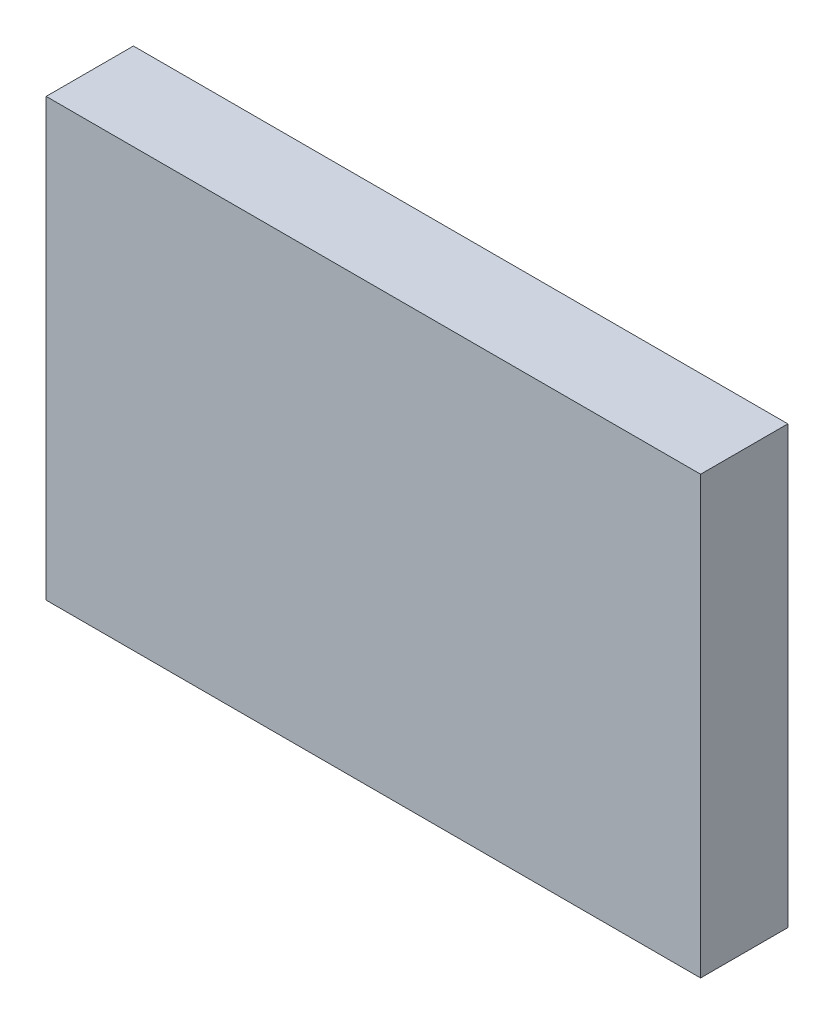
from build123d import *

# Parameters (mm, degrees)
SKETCH1_W      = 150
SKETCH1_H      = 100
EXTRUDE1_DEPTH = 20


with BuildPart() as part:
    # Sketch1 → Extrude1 (new body)
    with BuildSketch(Plane.XY):
        Rectangle(SKETCH1_W, SKETCH1_H)
    extrude(amount=EXTRUDE1_DEPTH)


solid = part.part
